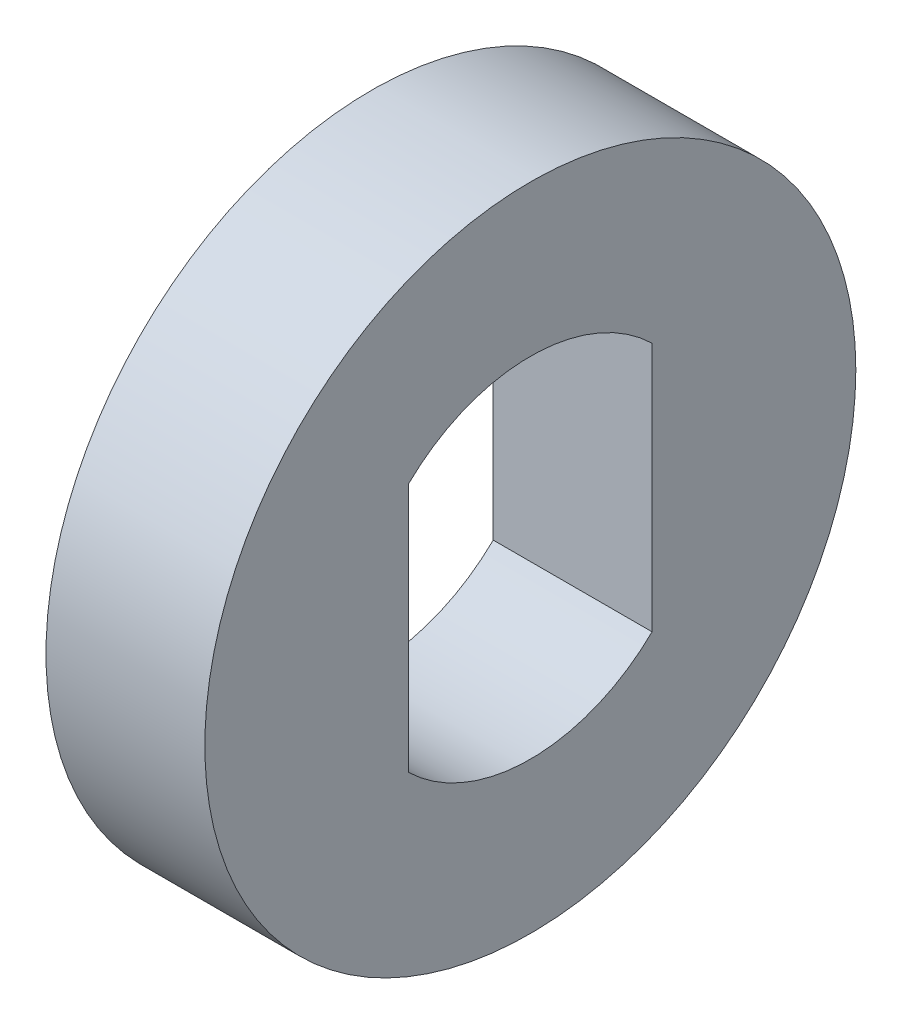
from build123d import *

# Parameters (mm, degrees)
CROQUIS1_R              = 5
SALIENTE_EXTRUIR1_DEPTH = 2.44


with BuildPart() as part:
    # Croquis1 → Saliente-Extruir1 (new body)
    with BuildSketch(Plane(origin=(0, 0, 0), x_dir=(0, 0, -1), z_dir=(1, 0, 0))):
        Circle(CROQUIS1_R)
        with BuildLine():
            Line((-1.87, 1.919765611), (-1.87, -1.919765611))
            ThreePointArc((-1.87, -1.919765611), (0, -2.68), (1.87, -1.919765611))
            Line((1.87, -1.919765611), (1.87, 1.919765611))
            ThreePointArc((1.87, 1.919765611), (0, 2.68), (-1.87, 1.919765611))
        make_face(mode=Mode.SUBTRACT)
    extrude(amount=SALIENTE_EXTRUIR1_DEPTH)


solid = part.part
